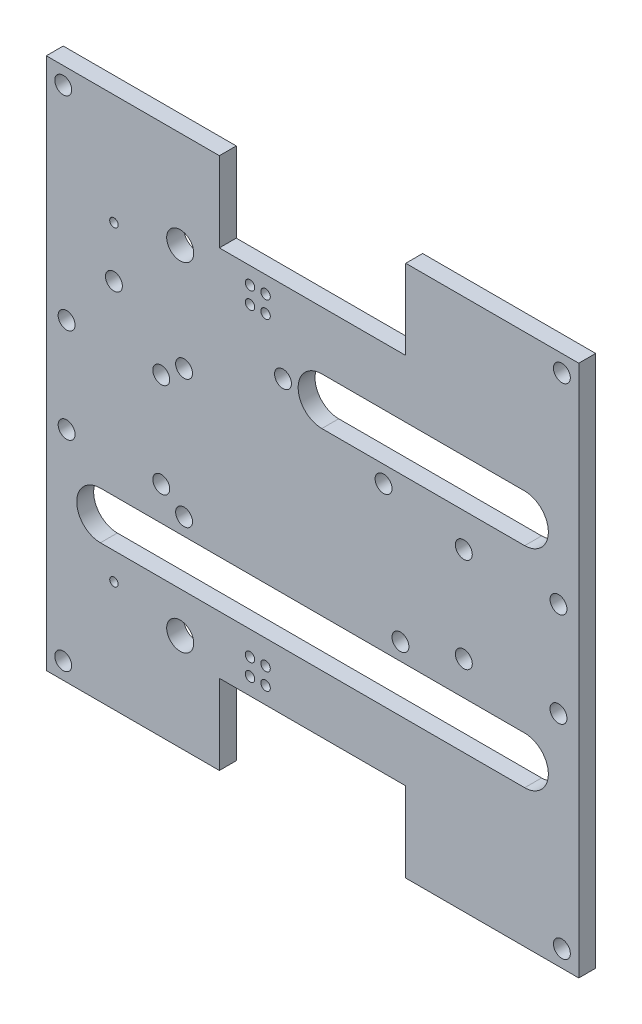
from build123d import *

# Parameters (mm, degrees)
SKETCH1_R           = 1.5875
SKETCH1_R_2         = 3.175
SKETCH1_R_3         = 1.778
SKETCH1_R_4         = 5.08
BOSS_EXTRUDE1_DEPTH = 6.35


with BuildPart() as part:
    # Sketch1 → Boss-Extrude1 (new body)
    with BuildSketch(Plane.XY):
        Polygon((249.789850187, 155.320558714), (314.789850187, 155.320558714), (314.789850187, -44.679441286), (249.789850187, -44.679441286), (249.789850187, -14.679441286), (179.789850187, -14.679441286), (179.789850187, -44.679441286), (114.789850187, -44.679441286), (114.789850187, 155.320558714), (179.789850187, 155.320558714), (179.789850187, 125.320558714), (249.789850187, 125.320558714), align=None)
        with Locations((140.189850187, -3.099441286)):
            Circle(SKETCH1_R, mode=Mode.SUBTRACT)
        with Locations((122.409850187, 73.100558714)):
            Circle(SKETCH1_R_2, mode=Mode.SUBTRACT)
        with Locations((122.409850187, 37.540558714)):
            Circle(SKETCH1_R_2, mode=Mode.SUBTRACT)
        with Locations((157.969850187, 37.540558714)):
            Circle(SKETCH1_R_2, mode=Mode.SUBTRACT)
        with Locations((140.189850187, 113.740558714)):
            Circle(SKETCH1_R, mode=Mode.SUBTRACT)
        with Locations((157.969850187, 73.100558714)):
            Circle(SKETCH1_R_2, mode=Mode.SUBTRACT)
        with Locations((271.609850187, 73.100558714)):
            Circle(SKETCH1_R_2, mode=Mode.SUBTRACT)
        with Locations((307.169850187, 73.100558714)):
            Circle(SKETCH1_R_2, mode=Mode.SUBTRACT)
        with Locations((271.609850187, 37.540558714)):
            Circle(SKETCH1_R_2, mode=Mode.SUBTRACT)
        with Locations((307.169850187, 37.540558714)):
            Circle(SKETCH1_R_2, mode=Mode.SUBTRACT)
        with Locations((121.139850187, 148.970558714)):
            Circle(SKETCH1_R_2, mode=Mode.SUBTRACT)
        with Locations((140.189850187, 94.677220113)):
            Circle(SKETCH1_R_2, mode=Mode.SUBTRACT)
        with Locations((203.689850187, 94.677220113)):
            Circle(SKETCH1_R_2, mode=Mode.SUBTRACT)
        with Locations((191.294850187, -1.979441286)):
            Circle(SKETCH1_R_3, mode=Mode.SUBTRACT)
        with Locations((197.136850187, -1.979441286)):
            Circle(SKETCH1_R_3, mode=Mode.SUBTRACT)
        with Locations((191.294850187, -8.329441286)):
            Circle(SKETCH1_R_3, mode=Mode.SUBTRACT)
        with Locations((197.136850187, -8.329441286)):
            Circle(SKETCH1_R_3, mode=Mode.SUBTRACT)
        with Locations((191.294850187, 118.970558714)):
            Circle(SKETCH1_R_3, mode=Mode.SUBTRACT)
        with Locations((191.294850187, 112.620558714)):
            Circle(SKETCH1_R_3, mode=Mode.SUBTRACT)
        with Locations((197.136850187, 112.620558714)):
            Circle(SKETCH1_R_3, mode=Mode.SUBTRACT)
        with Locations((197.136850187, 118.970558714)):
            Circle(SKETCH1_R_3, mode=Mode.SUBTRACT)
        with Locations((166.529850187, 79.450558714)):
            Circle(SKETCH1_R_2, mode=Mode.SUBTRACT)
        with Locations((241.459850187, 79.450558714)):
            Circle(SKETCH1_R_2, mode=Mode.SUBTRACT)
        with Locations((166.529850187, 31.190558714)):
            Circle(SKETCH1_R_2, mode=Mode.SUBTRACT)
        with Locations((247.809850187, 31.190558714)):
            Circle(SKETCH1_R_2, mode=Mode.SUBTRACT)
        with Locations((121.139850187, -38.329441286)):
            Circle(SKETCH1_R_2, mode=Mode.SUBTRACT)
        with Locations((308.439850187, -38.329441286)):
            Circle(SKETCH1_R_2, mode=Mode.SUBTRACT)
        with Locations((308.439850187, 148.970558714)):
            Circle(SKETCH1_R_2, mode=Mode.SUBTRACT)
        with Locations((165.076665974, 118.820558714)):
            Circle(SKETCH1_R_4, mode=Mode.SUBTRACT)
        with Locations((165.076665974, -8.179441286)):
            Circle(SKETCH1_R_4, mode=Mode.SUBTRACT)
        with BuildLine():
            Line((135.109850187, 24.840558714), (294.469850187, 24.840558714))
            ThreePointArc((294.469850187, 24.840558714), (303.359850187, 15.950558714), (294.469850187, 7.060558714))
            Line((294.469850187, 7.060558714), (135.109850187, 7.060558714))
            ThreePointArc((135.109850187, 7.060558714), (126.219850187, 15.950558714), (135.109850187, 24.840558714))
        make_face(mode=Mode.SUBTRACT)
        with BuildLine():
            Line((218.269850187, 103.580558714), (294.469850187, 103.580558714))
            ThreePointArc((294.469850187, 103.580558714), (303.359850187, 94.690558714), (294.469850187, 85.800558714))
            Line((294.469850187, 85.800558714), (218.269850187, 85.800558714))
            ThreePointArc((218.269850187, 85.800558714), (209.379850187, 94.690558714), (218.269850187, 103.580558714))
        make_face(mode=Mode.SUBTRACT)
    extrude(amount=BOSS_EXTRUDE1_DEPTH)


solid = part.part
